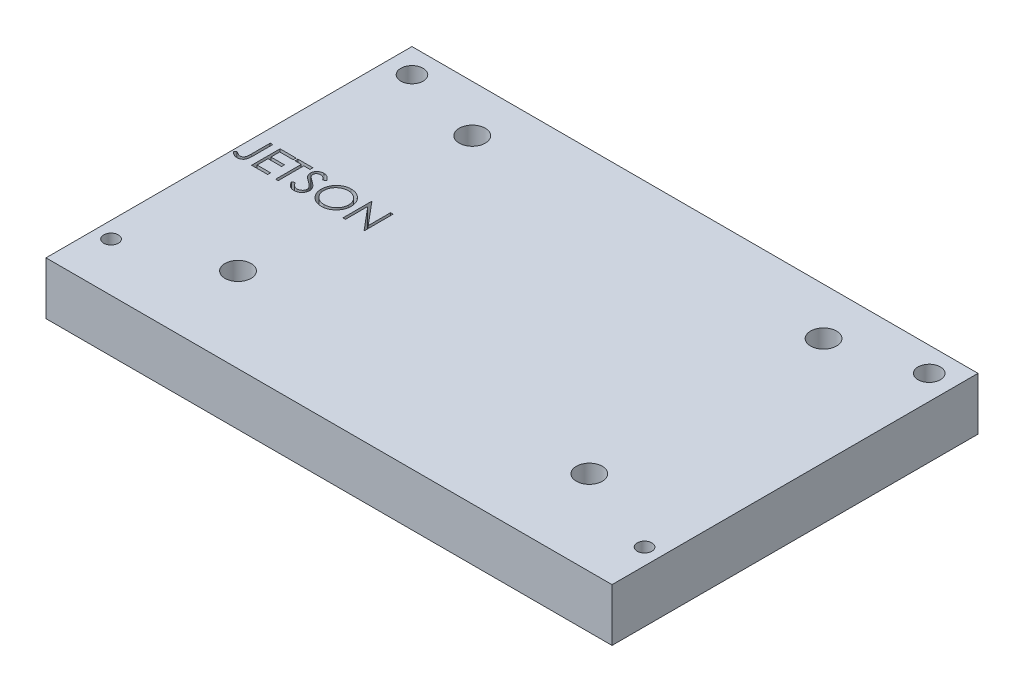
from build123d import *

# Parameters (mm, degrees)
SKETCH1_W           = 69.6
SKETCH1_H           = 45
SKETCH1_R           = 0.9
SKETCH1_R_2         = 1.375
SKETCH1_R_3         = 1.6
BOSS_EXTRUDE1_DEPTH = 6.48
CUT_EXTRUDE1_DEPTH  = 7.48


with BuildPart() as part:
    # Sketch1 → Boss-Extrude1 (new body)
    with BuildSketch(Plane(origin=(0, 0, 0), x_dir=(1, 0, 0), z_dir=(0, 1, 0))):
        with Locations((32.8, 16.5)):
            Rectangle(SKETCH1_W, SKETCH1_H)
        Circle(SKETCH1_R, mode=Mode.SUBTRACT)
        with Locations((1, 36)):
            Circle(SKETCH1_R_2, mode=Mode.SUBTRACT)
        with Locations((65.6, 0)):
            Circle(SKETCH1_R, mode=Mode.SUBTRACT)
        with Locations((64.6, 36)):
            Circle(SKETCH1_R_2, mode=Mode.SUBTRACT)
        with Locations((11.2, 4.41)):
            Circle(SKETCH1_R_3, mode=Mode.SUBTRACT)
        with Locations((11.2, 33.21)):
            Circle(SKETCH1_R_3, mode=Mode.SUBTRACT)
        with Locations((54.4, 33.21)):
            Circle(SKETCH1_R_3, mode=Mode.SUBTRACT)
        with Locations((54.4, 4.41)):
            Circle(SKETCH1_R_3, mode=Mode.SUBTRACT)
    extrude(amount=BOSS_EXTRUDE1_DEPTH)

    # Sketch2 → Cut-Extrude1 (cut, through all)
    with BuildSketch(Plane(origin=(0, 6.48, 0), x_dir=(1, 0, 0), z_dir=(0, 1, 0))):
        with BuildLine():
            Line((-0.429487179, 20), (-0.115384615, 20))
            Line((-0.115384615, 20), (-0.115384615, 17.636518429))
            add(Edge.make_bspline(
                [(-0.115384615, 17.636518429), (-0.115698534, 17.592813259), (-0.116301296, 17.508893997), (-0.119615707, 17.388020102), (-0.125749185, 17.277649415), (-0.134684197, 17.177530968), (-0.14660443, 17.087978413), (-0.160245458, 17.008299795), (-0.176758257, 16.939160113), (-0.201624723, 16.861524757), (-0.242398672, 16.776380952), (-0.30376571, 16.684425802), (-0.379998506, 16.603992391), (-0.468299539, 16.534139666), (-0.569440563, 16.478482435), (-0.681338783, 16.438527257), (-0.80330537, 16.4141564), (-0.887904582, 16.411582495), (-0.931490385, 16.41025641)],
                knots=[0, 0, 0, 0, 0.000131117, 0.000251761, 0.000362718, 0.000462694, 0.000553225, 0.000633683, 0.000705105, 0.0007663, 0.000877952, 0.000987044, 0.001096663, 0.001209011, 0.001323554, 0.00144132, 0.001564246, 0.001694883, 0.001694883, 0.001694883, 0.001694883], degree=3))
            add(Edge.make_bspline(
                [(-0.931490385, 16.41025641), (-0.965448743, 16.411337019), (-1.033775209, 16.413511277), (-1.135465918, 16.43123299), (-1.236867893, 16.458549033), (-1.338519342, 16.498551628), (-1.442428584, 16.552957227), (-1.55000293, 16.624142043), (-1.662626121, 16.71197357), (-1.736809407, 16.779011315), (-1.775641026, 16.814102564)],
                knots=[0, 0, 0, 0, 0.000101817, 0.000204863, 0.000308785, 0.000416459, 0.000531862, 0.000660014, 0.000802922, 0.000959898, 0.000959898, 0.000959898, 0.000959898], degree=3))
            Line((-1.775641026, 16.814102564), (-1.590544872, 17.083333333))
            add(Edge.make_bspline(
                [(-1.590544872, 17.083333333), (-1.547842193, 17.053885937), (-1.467213967, 16.998285413), (-1.348709526, 16.926758813), (-1.243712373, 16.865433647), (-1.175029425, 16.834181368), (-1.143229167, 16.819711538)],
                knots=[0, 0, 0, 0, 0.000155567, 0.000293731, 0.000415221, 0.00051997, 0.00051997, 0.00051997, 0.00051997], degree=3))
            add(Edge.make_bspline(
                [(-1.143229167, 16.819711538), (-1.123944855, 16.812152081), (-1.086124026, 16.797326302), (-1.028298946, 16.780780404), (-0.970803909, 16.771737994), (-0.932686215, 16.770056661), (-0.91396234, 16.769230769)],
                knots=[0, 0, 0, 0, 6.212e-05, 0.00012183, 0.00018004, 0.000236239, 0.000236239, 0.000236239, 0.000236239], degree=3))
            add(Edge.make_bspline(
                [(-0.91396234, 16.769230769), (-0.889779551, 16.770253504), (-0.841979095, 16.772275074), (-0.772515101, 16.790124349), (-0.70605707, 16.817368752), (-0.644987412, 16.857260046), (-0.588702025, 16.904691467), (-0.542259199, 16.962047475), (-0.503541955, 17.025613459), (-0.480242262, 17.085784913), (-0.46539749, 17.140661544), (-0.455975863, 17.191094679), (-0.447737202, 17.250056158), (-0.44055565, 17.317616358), (-0.43635118, 17.39391054), (-0.431633907, 17.478714683), (-0.429928646, 17.572242596), (-0.429638825, 17.637453547), (-0.429487179, 17.671574519)],
                knots=[0, 0, 0, 0, 7.2433e-05, 0.000143173, 0.000213879, 0.000287011, 0.000361082, 0.000433796, 0.000507383, 0.000583548, 0.000626408, 0.000677834, 0.000737327, 0.000804999, 0.000881578, 0.000966518, 0.001059791, 0.001162157, 0.001162157, 0.001162157, 0.001162157], degree=3))
            Line((-0.429487179, 17.671574519), (-0.429487179, 20))
        make_face()
        Polygon((0.782051282, 20), (2.756410256, 20), (2.756410256, 19.641025641), (1.096153846, 19.641025641), (1.096153846, 18.564102564), (2.756410256, 18.564102564), (2.756410256, 18.205128205), (1.096153846, 18.205128205), (1.096153846, 16.858974359), (2.756410256, 16.858974359), (2.756410256, 16.5), (0.782051282, 16.5), align=None)
        Polygon((2.980769231, 19.641025641), (2.980769231, 20), (4.820512821, 20), (4.820512821, 19.641025641), (4.057692308, 19.641025641), (4.057692308, 16.5), (3.743589744, 16.5), (3.743589744, 19.641025641), align=None)
        with BuildLine():
            Line((5, 17.175180288), (5.295873397, 17.352564103))
            add(Edge.make_bspline(
                [(5.295873397, 17.352564103), (5.323391635, 17.306499718), (5.376115515, 17.218242134), (5.464066874, 17.098984093), (5.555199786, 16.997621937), (5.650189119, 16.914745329), (5.748455067, 16.849496442), (5.850639121, 16.803294211), (5.956396932, 16.774478235), (6.028370753, 16.770978149), (6.064302885, 16.769230769)],
                knots=[0, 0, 0, 0, 0.000160901, 0.00030828, 0.000443778, 0.00056903, 0.000685513, 0.000796284, 0.00090427, 0.001011928, 0.001011928, 0.001011928, 0.001011928], degree=3))
            add(Edge.make_bspline(
                [(6.064302885, 16.769230769), (6.094989745, 16.770085442), (6.155826518, 16.771779832), (6.245388761, 16.788060634), (6.332370563, 16.813072763), (6.414979201, 16.848893694), (6.492074816, 16.89223218), (6.559681511, 16.944578358), (6.618127624, 17.003184563), (6.665936739, 17.068567218), (6.702616774, 17.138884367), (6.730808842, 17.211060318), (6.746453916, 17.286228886), (6.74881067, 17.336839349), (6.75, 17.362379808)],
                knots=[0, 0, 0, 0, 9.1978e-05, 0.000182347, 0.000272202, 0.000362975, 0.000451852, 0.000536835, 0.000618639, 0.000699414, 0.000778765, 0.000855983, 0.0009312, 0.001007828, 0.001007828, 0.001007828, 0.001007828], degree=3))
            add(Edge.make_bspline(
                [(6.75, 17.362379808), (6.748525689, 17.391520657), (6.745528631, 17.450759747), (6.720197151, 17.5381594), (6.680347904, 17.62465197), (6.64358526, 17.678153235), (6.624499199, 17.705929487)],
                knots=[0, 0, 0, 0, 8.7281e-05, 0.000177429, 0.000270909, 0.000371844, 0.000371844, 0.000371844, 0.000371844], degree=3))
            add(Edge.make_bspline(
                [(6.624499199, 17.705929487), (6.608828585, 17.725976311), (6.57593009, 17.768062109), (6.519372578, 17.830707345), (6.453006463, 17.895325764), (6.379102908, 17.964384821), (6.29496982, 18.034672617), (6.203242305, 18.109540895), (6.101578446, 18.186142472), (6.03027895, 18.237515038), (5.993489583, 18.264022436)],
                knots=[0, 0, 0, 0, 7.6319e-05, 0.000160223, 0.000252933, 0.000354147, 0.000463581, 0.000581729, 0.000709336, 0.000845369, 0.000845369, 0.000845369, 0.000845369], degree=3))
            add(Edge.make_bspline(
                [(5.993489583, 18.264022436), (5.956665587, 18.290251024), (5.886260911, 18.340398086), (5.787802328, 18.41482237), (5.699757865, 18.482866239), (5.622518849, 18.545170251), (5.556119252, 18.601742856), (5.500035841, 18.652040795), (5.455697284, 18.697424356), (5.431041703, 18.726865698), (5.419971955, 18.740084135)],
                knots=[0, 0, 0, 0, 0.000135623, 0.000259301, 0.000370234, 0.000469439, 0.00055697, 0.000631911, 0.000695377, 0.00074709, 0.00074709, 0.00074709, 0.00074709], degree=3))
            add(Edge.make_bspline(
                [(5.419971955, 18.740084135), (5.40449941, 18.760685171), (5.374070573, 18.801199875), (5.333904568, 18.864524733), (5.299765405, 18.929347998), (5.273003073, 18.995843863), (5.250466854, 19.063078792), (5.235308923, 19.131930038), (5.225817526, 19.202088656), (5.22484554, 19.249302157), (5.224358974, 19.272936699)],
                knots=[0, 0, 0, 0, 7.727e-05, 0.000151962, 0.000224716, 0.000296717, 0.00036678, 0.0004372, 0.000507902, 0.000578771, 0.000578771, 0.000578771, 0.000578771], degree=3))
            add(Edge.make_bspline(
                [(5.224358974, 19.272936699), (5.225664183, 19.309966473), (5.228246703, 19.383234537), (5.250087221, 19.490265367), (5.284560114, 19.592451785), (5.332855002, 19.688782118), (5.395112355, 19.776748099), (5.467158329, 19.857361586), (5.552969816, 19.925130168), (5.647122439, 19.984342227), (5.750178811, 20.030688152), (5.858169714, 20.065649132), (5.971266786, 20.08545839), (6.047869921, 20.088301155), (6.086738782, 20.08974359)],
                knots=[0, 0, 0, 0, 0.000110999, 0.000219625, 0.000326272, 0.00043382, 0.000541574, 0.000648775, 0.000756959, 0.000868438, 0.000981703, 0.00109501, 0.001208203, 0.0013248, 0.0013248, 0.0013248, 0.0013248], degree=3))
            add(Edge.make_bspline(
                [(6.086738782, 20.08974359), (6.127982882, 20.088321038), (6.210004234, 20.085492037), (6.33065345, 20.060894506), (6.446814166, 20.020193834), (6.540257431, 19.974005176), (6.613390192, 19.92787376), (6.669162925, 19.885853936), (6.725680376, 19.837478827), (6.783398431, 19.782619581), (6.84133909, 19.72077283), (6.900362542, 19.652362141), (6.960606811, 19.577805585), (6.999362671, 19.524581085), (7.019230769, 19.497295673)],
                knots=[0, 0, 0, 0, 0.000123638, 0.000245877, 0.000367608, 0.000492088, 0.000557638, 0.000626769, 0.000701372, 0.00078072, 0.000865532, 0.000955497, 0.001051745, 0.001152989, 0.001152989, 0.001152989, 0.001152989], degree=3))
            Line((7.019230769, 19.497295673), (6.735276442, 19.282051282))
            add(Edge.make_bspline(
                [(6.735276442, 19.282051282), (6.71813051, 19.304139972), (6.685111453, 19.346677626), (6.634981966, 19.406248941), (6.587733318, 19.460665421), (6.541182918, 19.507930549), (6.497789287, 19.550632682), (6.455672244, 19.587192439), (6.415437893, 19.617968034), (6.364720983, 19.650811594), (6.301003264, 19.683368098), (6.221018728, 19.710917176), (6.137432453, 19.727472238), (6.080502822, 19.729661126), (6.051682692, 19.730769231)],
                knots=[0, 0, 0, 0, 8.3877e-05, 0.000161528, 0.000233552, 0.000299993, 0.000360485, 0.000416152, 0.000467195, 0.000512312, 0.000597287, 0.000681099, 0.000765389, 0.000851809, 0.000851809, 0.000851809, 0.000851809], degree=3))
            add(Edge.make_bspline(
                [(6.051682692, 19.730769231), (6.01552617, 19.729557531), (5.945801722, 19.727220882), (5.846811486, 19.701700896), (5.757717561, 19.661519036), (5.681164996, 19.605204058), (5.617428019, 19.538483065), (5.57132256, 19.46170421), (5.543572396, 19.376921808), (5.540186116, 19.317780151), (5.538461538, 19.287660256)],
                knots=[0, 0, 0, 0, 0.000108248, 0.000208746, 0.00030443, 0.000399793, 0.000492054, 0.00057947, 0.000666386, 0.000756591, 0.000756591, 0.000756591, 0.000756591], degree=3))
            add(Edge.make_bspline(
                [(5.538461538, 19.287660256), (5.538854665, 19.268908778), (5.539641561, 19.231375158), (5.550616359, 19.175923736), (5.564715688, 19.120612397), (5.58705832, 19.065689814), (5.617903623, 19.010195455), (5.658408799, 18.953173718), (5.709422111, 18.894122009), (5.748499124, 18.855714635), (5.769130609, 18.835436699)],
                knots=[0, 0, 0, 0, 5.616e-05, 0.000112411, 0.000169046, 0.000227244, 0.000289691, 0.000359134, 0.000436702, 0.000523463, 0.000523463, 0.000523463, 0.000523463], degree=3))
            add(Edge.make_bspline(
                [(5.769130609, 18.835436699), (5.776791981, 18.828599673), (5.794993649, 18.812356465), (5.828269574, 18.785764184), (5.872212372, 18.752961412), (5.925674574, 18.712374095), (5.989641935, 18.665292633), (6.064121492, 18.612319021), (6.148283024, 18.551733562), (6.20800494, 18.509376021), (6.239583333, 18.486979167)],
                knots=[0, 0, 0, 0, 3.0802e-05, 7.3177e-05, 0.000127725, 0.000195314, 0.000274544, 0.000365991, 0.000469501, 0.000585644, 0.000585644, 0.000585644, 0.000585644], degree=3))
            add(Edge.make_bspline(
                [(6.239583333, 18.486979167), (6.277569247, 18.459337807), (6.351123703, 18.405814145), (6.455781283, 18.325398465), (6.550675091, 18.246750697), (6.636138295, 18.17037309), (6.713015203, 18.096844997), (6.780452924, 18.025281816), (6.839138604, 17.956196244), (6.902317823, 17.867623668), (6.966875642, 17.758842584), (7.022317149, 17.625564345), (7.057275497, 17.491768025), (7.061847012, 17.401841188), (7.064102564, 17.357471955)],
                knots=[0, 0, 0, 0, 0.000140932, 0.000272896, 0.000395881, 0.000510584, 0.000616697, 0.000714904, 0.000805482, 0.000888372, 0.001041088, 0.001183793, 0.001320341, 0.001453327, 0.001453327, 0.001453327, 0.001453327], degree=3))
            add(Edge.make_bspline(
                [(7.064102564, 17.357471955), (7.063445426, 17.32609359), (7.062143911, 17.263946206), (7.047182997, 17.17269113), (7.025263332, 17.08406026), (6.992226098, 16.999149147), (6.95190294, 16.916404385), (6.900736692, 16.837996484), (6.841429007, 16.762190086), (6.773395242, 16.691006594), (6.69894934, 16.625660398), (6.620265645, 16.567531337), (6.537215372, 16.519063014), (6.450249056, 16.479512172), (6.359346719, 16.448578654), (6.264538935, 16.426165785), (6.165669424, 16.412410074), (6.098468942, 16.410982313), (6.064302885, 16.41025641)],
                knots=[0, 0, 0, 0, 9.4044e-05, 0.000186263, 0.000276729, 0.000367488, 0.000459046, 0.000552398, 0.000647774, 0.000747454, 0.000847311, 0.000944634, 0.001040472, 0.001135227, 0.001230788, 0.001328063, 0.00142712, 0.00152957, 0.00152957, 0.00152957, 0.00152957], degree=3))
            add(Edge.make_bspline(
                [(6.064302885, 16.41025641), (6.037867542, 16.410767592), (5.985329782, 16.411783517), (5.9076203, 16.420764798), (5.831480711, 16.433471901), (5.757866428, 16.453645971), (5.685829017, 16.478122948), (5.615681782, 16.508261281), (5.547390728, 16.544378482), (5.480573146, 16.585673507), (5.415398971, 16.633731252), (5.352479503, 16.689704748), (5.289750318, 16.752050253), (5.229062921, 16.822460816), (5.169189777, 16.899798899), (5.111311367, 16.984788083), (5.05422965, 17.076965436), (5.018414182, 17.141830522), (5, 17.175180288)],
                knots=[0, 0, 0, 0, 7.9276e-05, 0.000157554, 0.000234438, 0.000310629, 0.000386236, 0.000462555, 0.000539392, 0.000617798, 0.000698008, 0.000781971, 0.000870217, 0.00096315, 0.001060616, 0.001163492, 0.001271478, 0.00138575, 0.00138575, 0.00138575, 0.00138575], degree=3))
        make_face()
        with BuildLine():
            add(Edge.make_bspline(
                [(9.419871795, 20.08974359), (9.484679901, 20.08810211), (9.611968368, 20.084878109), (9.799043265, 20.060199006), (9.977638361, 20.017503616), (10.1492085, 19.960640633), (10.311701476, 19.884786248), (10.466340369, 19.7931011), (10.612757242, 19.684624641), (10.748978624, 19.560195414), (10.873635574, 19.42481196), (10.983461461, 19.28033405), (11.075503754, 19.127635248), (11.151089541, 18.967174417), (11.210388151, 18.799314449), (11.251307195, 18.623160446), (11.277445345, 18.439853756), (11.280501122, 18.314826892), (11.282051282, 18.251402244)],
                knots=[0, 0, 0, 0, 0.000194393, 0.000381804, 0.00056479, 0.000744601, 0.000923091, 0.001101652, 0.001283106, 0.001468738, 0.001654324, 0.001834514, 0.002012231, 0.002188181, 0.002365797, 0.002545211, 0.002729936, 0.002920126, 0.002920126, 0.002920126, 0.002920126], degree=3))
            add(Edge.make_bspline(
                [(11.282051282, 18.251402244), (11.28050135, 18.188444797), (11.277446253, 18.064348377), (11.251277475, 17.882204933), (11.210236475, 17.707114236), (11.151640209, 17.539368583), (11.076414731, 17.37879102), (10.98375956, 17.225804066), (10.874618349, 17.080357567), (10.750411498, 16.944044902), (10.615010456, 16.819047431), (10.469780189, 16.710128556), (10.317986869, 16.616404431), (10.157677161, 16.541620757), (9.990977124, 16.481848837), (9.816394801, 16.441096207), (9.634748247, 16.414809163), (9.510877243, 16.411790647), (9.447916667, 16.41025641)],
                knots=[0, 0, 0, 0, 0.000188789, 0.000372126, 0.000550857, 0.00072758, 0.000904164, 0.001081881, 0.001263191, 0.001448823, 0.00163441, 0.001815159, 0.001992641, 0.002168591, 0.002344885, 0.002522934, 0.002705576, 0.002894365, 0.002894365, 0.002894365, 0.002894365], degree=3))
            add(Edge.make_bspline(
                [(9.447916667, 16.41025641), (9.384492348, 16.411805797), (9.259466132, 16.414860051), (9.075929096, 16.441041456), (8.899651353, 16.48198276), (8.731137001, 16.540492196), (8.570292072, 16.616109427), (8.416801989, 16.708313806), (8.271282842, 16.817720947), (8.134941095, 16.941887521), (8.010191897, 17.077059073), (7.901432521, 17.221893329), (7.809207408, 17.373548785), (7.733844076, 17.532446309), (7.674179616, 17.697817752), (7.633474798, 17.870766229), (7.607138846, 18.050305735), (7.604104, 18.172548634), (7.602564103, 18.234575321)],
                knots=[0, 0, 0, 0, 0.00019019, 0.000374915, 0.000555011, 0.000732396, 0.00090898, 0.001087298, 0.001268608, 0.00145424, 0.001639827, 0.001819595, 0.001996712, 0.002171394, 0.002346367, 0.002523053, 0.002703612, 0.002889599, 0.002889599, 0.002889599, 0.002889599], degree=3))
            add(Edge.make_bspline(
                [(7.602564103, 18.234575321), (7.603098738, 18.27620799), (7.604161264, 18.358948113), (7.616952957, 18.481814713), (7.635514658, 18.602705371), (7.662116571, 18.721276319), (7.696908238, 18.837237304), (7.737960265, 18.951388067), (7.78810011, 19.06257179), (7.844780758, 19.171315182), (7.908042566, 19.275923088), (7.977918316, 19.374802671), (8.051953684, 19.468783668), (8.133117078, 19.555430672), (8.218733523, 19.637264328), (8.310191901, 19.713027045), (8.406934146, 19.783401996), (8.509376525, 19.846822337), (8.6149948, 19.904181472), (8.723871578, 19.953403323), (8.83452815, 19.995649384), (8.947482798, 20.029890209), (9.06243557, 20.056922245), (9.179637354, 20.075329599), (9.29899478, 20.088153917), (9.379406099, 20.089211419), (9.419871795, 20.08974359)],
                knots=[0, 0, 0, 0, 0.000124849, 0.000248123, 0.000370193, 0.00049164, 0.000612319, 0.000733199, 0.000855287, 0.000977905, 0.001100913, 0.001221706, 0.001340948, 0.001459521, 0.001577551, 0.001696047, 0.001815534, 0.001936153, 0.002057243, 0.002175846, 0.002294342, 0.002412335, 0.002529682, 0.00264829, 0.002768075, 0.00288942, 0.00288942, 0.00288942, 0.00288942], degree=3))
        make_face()
        with BuildLine():
            add(Edge.make_bspline(
                [(9.435296474, 19.730769231), (9.402081841, 19.730364341), (9.335970108, 19.729558431), (9.237685572, 19.718942715), (9.140693638, 19.703812826), (9.044974276, 19.682231305), (8.950927986, 19.652827253), (8.857678145, 19.618986345), (8.766075091, 19.577765254), (8.676421233, 19.53119255), (8.589506158, 19.479643629), (8.507493457, 19.422671862), (8.430170813, 19.361613307), (8.357727546, 19.29632547), (8.290376374, 19.226475868), (8.226791673, 19.153123432), (8.169522091, 19.074171541), (8.117036514, 18.991761134), (8.070068674, 18.905999553), (8.028303319, 18.817789691), (7.99413931, 18.726412004), (7.966276934, 18.632857846), (7.943177123, 18.537275387), (7.928543199, 18.438939538), (7.91781084, 18.338344426), (7.917050994, 18.270362572), (7.916666667, 18.235977564)],
                knots=[0, 0, 0, 0, 9.9599e-05, 0.000198245, 0.000296222, 0.00039402, 0.00049227, 0.000591646, 0.000691452, 0.000793368, 0.000894612, 0.000994383, 0.001092713, 0.00119001, 0.001286696, 0.001383657, 0.001480979, 0.001579008, 0.001676595, 0.001774142, 0.001871547, 0.001968922, 0.002066879, 0.00216624, 0.00226698, 0.002370083, 0.002370083, 0.002370083, 0.002370083], degree=3))
            add(Edge.make_bspline(
                [(7.916666667, 18.235977564), (7.917941529, 18.185415343), (7.920449576, 18.085943813), (7.942407147, 17.940175669), (7.976229121, 17.800087383), (8.026086487, 17.666445474), (8.088437102, 17.538101191), (8.165463992, 17.416193086), (8.256723078, 17.300688212), (8.360386605, 17.192392943), (8.473709311, 17.093547138), (8.594042041, 17.00678373), (8.720095649, 16.93337348), (8.852198851, 16.873568408), (8.98964639, 16.82617867), (9.133323941, 16.793700039), (9.282274401, 16.772324583), (9.383805056, 16.770271827), (9.435296474, 16.769230769)],
                knots=[0, 0, 0, 0, 0.000151605, 0.000298253, 0.000441263, 0.000583229, 0.000725274, 0.000868635, 0.001014928, 0.001166177, 0.001317744, 0.00146543, 0.001610576, 0.001754594, 0.001899821, 0.002045914, 0.002195936, 0.002350312, 0.002350312, 0.002350312, 0.002350312], degree=3))
            add(Edge.make_bspline(
                [(9.435296474, 16.769230769), (9.469905976, 16.769706274), (9.538547012, 16.770649342), (9.640642535, 16.780148018), (9.740898746, 16.795379888), (9.839175026, 16.817310543), (9.935359838, 16.84475775), (10.029854641, 16.877365478), (10.121652931, 16.918046682), (10.211912769, 16.962994633), (10.298309011, 17.014234791), (10.380784543, 17.06927294), (10.457260523, 17.130241561), (10.529649594, 17.194559374), (10.597277283, 17.263523221), (10.659686267, 17.337043443), (10.7166664, 17.4155841), (10.769132046, 17.497869506), (10.815935309, 17.583865759), (10.856714408, 17.672395437), (10.891310524, 17.763240546), (10.919239029, 17.856532118), (10.94112449, 17.952092966), (10.95620441, 18.050051045), (10.966752849, 18.150210387), (10.967547926, 18.217954243), (10.967948718, 18.252103365)],
                knots=[0, 0, 0, 0, 0.000103804, 0.000205874, 0.000307314, 0.000407849, 0.000507719, 0.000607281, 0.000707445, 0.000808723, 0.000909609, 0.001008589, 0.001105934, 0.001202762, 0.001298946, 0.001395452, 0.001491794, 0.001589823, 0.001688026, 0.001785277, 0.001882027, 0.001979402, 0.0020772, 0.002175869, 0.002276609, 0.002379011, 0.002379011, 0.002379011, 0.002379011], degree=3))
            add(Edge.make_bspline(
                [(10.967948718, 18.252103365), (10.967547605, 18.28601887), (10.966751923, 18.35329652), (10.956209449, 18.452757338), (10.941108558, 18.55001055), (10.91934585, 18.644674353), (10.891295697, 18.736772878), (10.856708366, 18.826219625), (10.815923067, 18.913347821), (10.769114842, 18.997942118), (10.716499019, 19.079116855), (10.659004776, 19.156719268), (10.595639428, 19.229292009), (10.528213403, 19.298626703), (10.455042517, 19.363244593), (10.376458223, 19.423167114), (10.293414546, 19.479840388), (10.20548731, 19.53096595), (10.114743356, 19.578180182), (10.021629398, 19.618631186), (9.927200299, 19.653003305), (9.831696186, 19.68232027), (9.734313208, 19.7037283), (9.635709379, 19.71895635), (9.536021121, 19.729554736), (9.468977901, 19.730363114), (9.435296474, 19.730769231)],
                knots=[0, 0, 0, 0, 0.000101701, 0.000201743, 0.00029972, 0.000396835, 0.000492868, 0.000588308, 0.000684288, 0.000781261, 0.000878109, 0.000974304, 0.001070733, 0.001166917, 0.001264269, 0.001363274, 0.001463228, 0.001565678, 0.001668217, 0.001769947, 0.001869982, 0.001969573, 0.002069423, 0.002168785, 0.002268827, 0.002369827, 0.002369827, 0.002369827, 0.002369827], degree=3))
        make_face(mode=Mode.SUBTRACT)
        Polygon((12, 16.5), (12, 20), (12.065905449, 20), (14.378205128, 17.245292468), (14.378205128, 20), (14.692307692, 20), (14.692307692, 16.5), (14.620793269, 16.5), (12.314102564, 19.248397436), (12.314102564, 16.5), align=None)
    extrude(amount=-CUT_EXTRUDE1_DEPTH, mode=Mode.SUBTRACT)


solid = part.part
